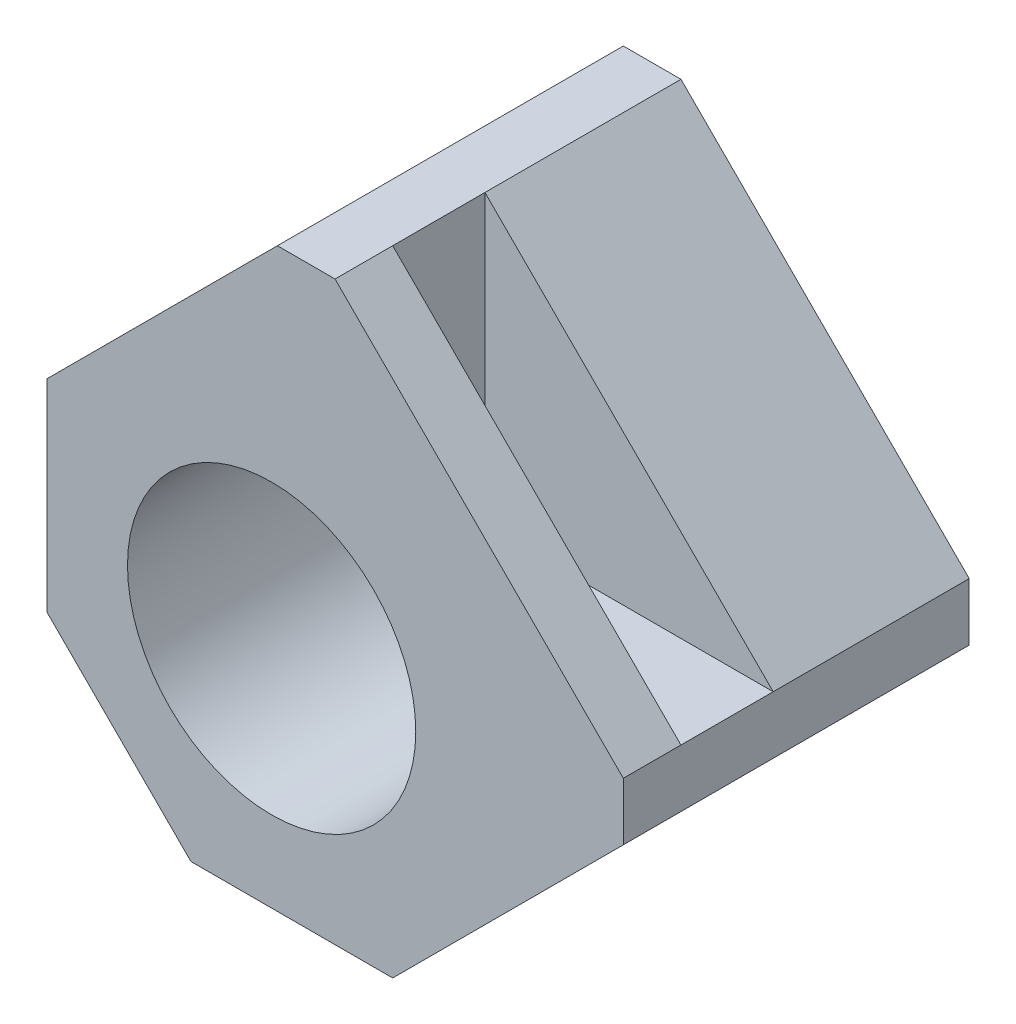
from build123d import *

# Parameters (mm, degrees)
ESQUISSE1_W             = 20
ESQUISSE1_H             = 20
BOSS_EXTRU_1_DEPTH      = 12
CHANFREIN1_SIZE         = 10
ENL_V_START             = -2
ENL_V_MAT_EXTRU_1_DEPTH = 3.2
ESQUISSE3_R             = 2.2
ENL_V_MAT_EXTRU_2_DEPTH = 13
ESQUISSE4_R             = 5
ENL_V_MAT_EXTRU_3_DEPTH = 10.5
CHANFREIN2_SIZE         = 5
CHANFREIN3_SIZE         = 8
SKETCH1_R               = 6
CUT_EXTRUDE1_DEPTH      = 0.5


with BuildPart() as part:
    # Esquisse1 → Boss.-Extru.1 (new body)
    with BuildSketch(Plane.XY):
        with Locations((10, 10)):
            Rectangle(ESQUISSE1_W, ESQUISSE1_H)
    extrude(amount=BOSS_EXTRU_1_DEPTH)

    # Chanfrein1
    chanfrein1_edges = [part.edges().sort_by_distance(p)[0] for p in [
        (20, 20, 6),
    ]]
    chamfer(chanfrein1_edges, length=CHANFREIN1_SIZE)

    # Esquisse2 → Enlèv. mat.-Extru.1 (cut)
    with BuildSketch(Plane.XY.offset(12).offset(ENL_V_START)):
        Polygon((10, 20), (10, 10), (20, 10), align=None)
    extrude(amount=-ENL_V_MAT_EXTRU_1_DEPTH, mode=Mode.SUBTRACT)

    # Esquisse3 → Enlèv. mat.-Extru.2 (cut, through all)
    with BuildSketch(Plane(origin=(0, 0, 0), x_dir=(-1, 0, 0), z_dir=(0, 0, -1))):
        with Locations((-7.8, 7.8)):
            Circle(ESQUISSE3_R)
    extrude(amount=-ENL_V_MAT_EXTRU_2_DEPTH, mode=Mode.SUBTRACT)

    # Esquisse4 → Enlèv. mat.-Extru.3 (cut)
    with BuildSketch(Plane.XY.offset(12)):
        with Locations((7.8, 7.8)):
            Circle(ESQUISSE4_R)
    extrude(amount=-ENL_V_MAT_EXTRU_3_DEPTH, mode=Mode.SUBTRACT)

    # Chanfrein2
    chanfrein2_edges = [part.edges().sort_by_distance(p)[0] for p in [
        (0, 0, 6),
    ]]
    chamfer(chanfrein2_edges, length=CHANFREIN2_SIZE)

    # Chanfrein3
    chanfrein3_edges = [part.edges().sort_by_distance(p)[0] for p in [
        (0, 20, 6),
        (20, 0, 6),
    ]]
    chamfer(chanfrein3_edges, length=CHANFREIN3_SIZE)

    # Sketch1 → Cut-Extrude1 (cut)
    with BuildSketch(Plane(origin=(0, 0, 0), x_dir=(-1, 0, 0), z_dir=(0, 0, -1))):
        with Locations((-7.8, 7.8)):
            Circle(SKETCH1_R)
    extrude(amount=-CUT_EXTRUDE1_DEPTH, mode=Mode.SUBTRACT)


solid = part.part
